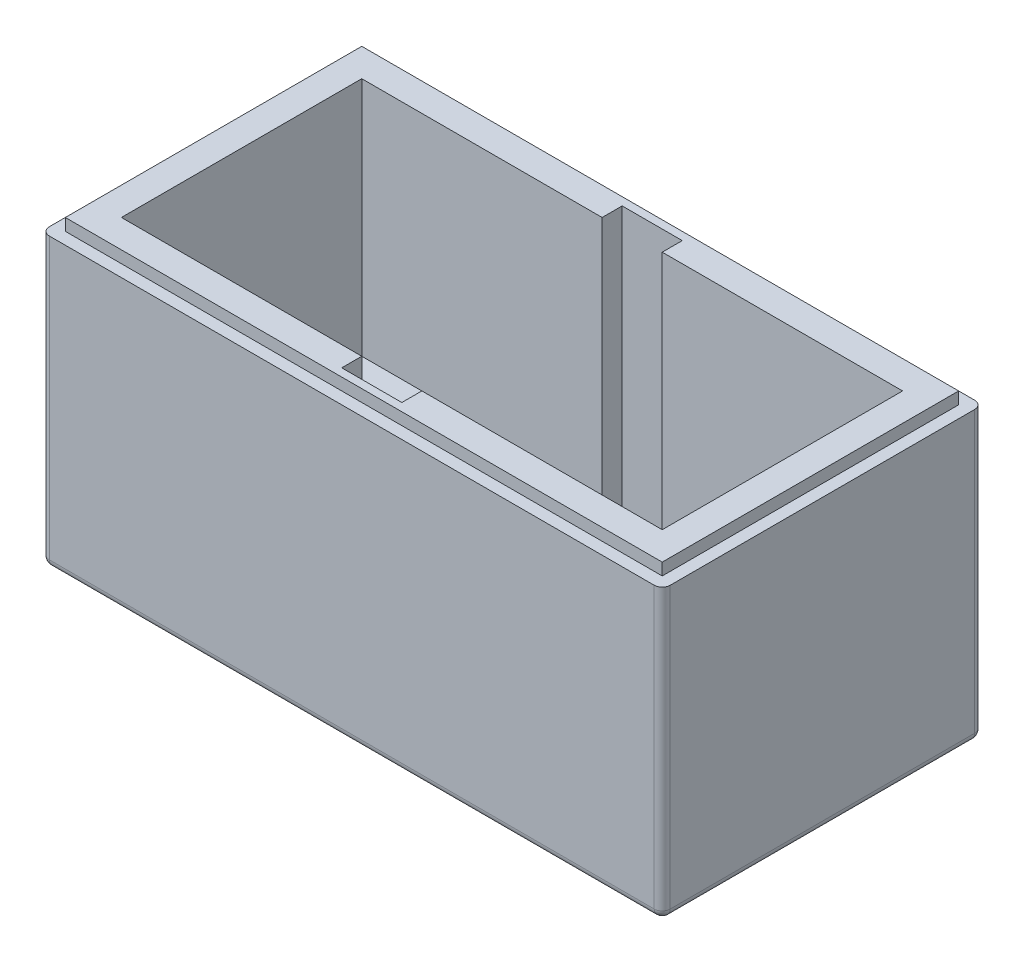
from build123d import *

# Parameters (mm, degrees)
SKETCH2_W           = 155
SKETCH2_H           = 80
BOSS_EXTRUDE1_DEPTH = 15
SKETCH3_W           = 15
SKETCH3_H           = 70
CUT_EXTRUDE1_DEPTH  = 5
SKETCH4_W           = 155
SKETCH4_H           = 80
BOSS_EXTRUDE3_DEPTH = 60
SKETCH5_W           = 155
SKETCH5_H           = 80
SKETCH5_W_2         = 149
SKETCH5_H_2         = 74
CUT_EXTRUDE2_DEPTH  = 3
FILLET1_R           = 2


with BuildPart() as part:
    # Sketch2 → Boss-Extrude1 (new body)
    with BuildSketch(Plane(origin=(0, 0, 0), x_dir=(1, 0, 0), z_dir=(0, 1, 0))):
        with Locations((-77.5, -40)):
            Rectangle(SKETCH2_W, SKETCH2_H)
    extrude(amount=BOSS_EXTRUDE1_DEPTH)

    # Sketch3 → Cut-Extrude1 (cut)
    with BuildSketch(Plane(origin=(0, 15, 0), x_dir=(1, 0, 0), z_dir=(0, 1, 0))):
        with Locations((-77.5, -40)):
            Rectangle(SKETCH3_W, SKETCH3_H)
    extrude(amount=-CUT_EXTRUDE1_DEPTH, mode=Mode.SUBTRACT)

    # Sketch4 → Boss-Extrude3 (add)
    with BuildSketch(Plane(origin=(0, 15, 0), x_dir=(1, 0, 0), z_dir=(0, 1, 0))):
        with Locations((-77.5, -40)):
            Rectangle(SKETCH4_W, SKETCH4_H)
        Polygon((-145, -10), (-145, -70), (-85, -70), (-85, -75), (-70, -75), (-70, -70), (-10, -70), (-10, -10), (-70, -10), (-70, -5), (-85, -5), (-85, -10), align=None, mode=Mode.SUBTRACT)
    extrude(amount=BOSS_EXTRUDE3_DEPTH)

    # Sketch5 → Cut-Extrude2 (cut)
    with BuildSketch(Plane(origin=(0, 75, 0), x_dir=(1, 0, 0), z_dir=(0, 1, 0))):
        with Locations((-77.5, -40)):
            Rectangle(SKETCH5_W, SKETCH5_H)
        with Locations((-77.5, -40)):
            Rectangle(SKETCH5_W_2, SKETCH5_H_2, mode=Mode.SUBTRACT)
    extrude(amount=-CUT_EXTRUDE2_DEPTH, mode=Mode.SUBTRACT)

    # Fillet1
    fillet1_edges = [part.edges().sort_by_distance(p)[0] for p in [
        (-77.5, 0, 80),
        (-155, 0, 40),
        (-77.5, 0, 0),
        (0, 0, 40),
        (0, 36, 0),
        (0, 36, 80),
        (-155, 36, 0),
        (-155, 36, 80),
    ]]
    fillet(fillet1_edges, radius=FILLET1_R)


solid = part.part
